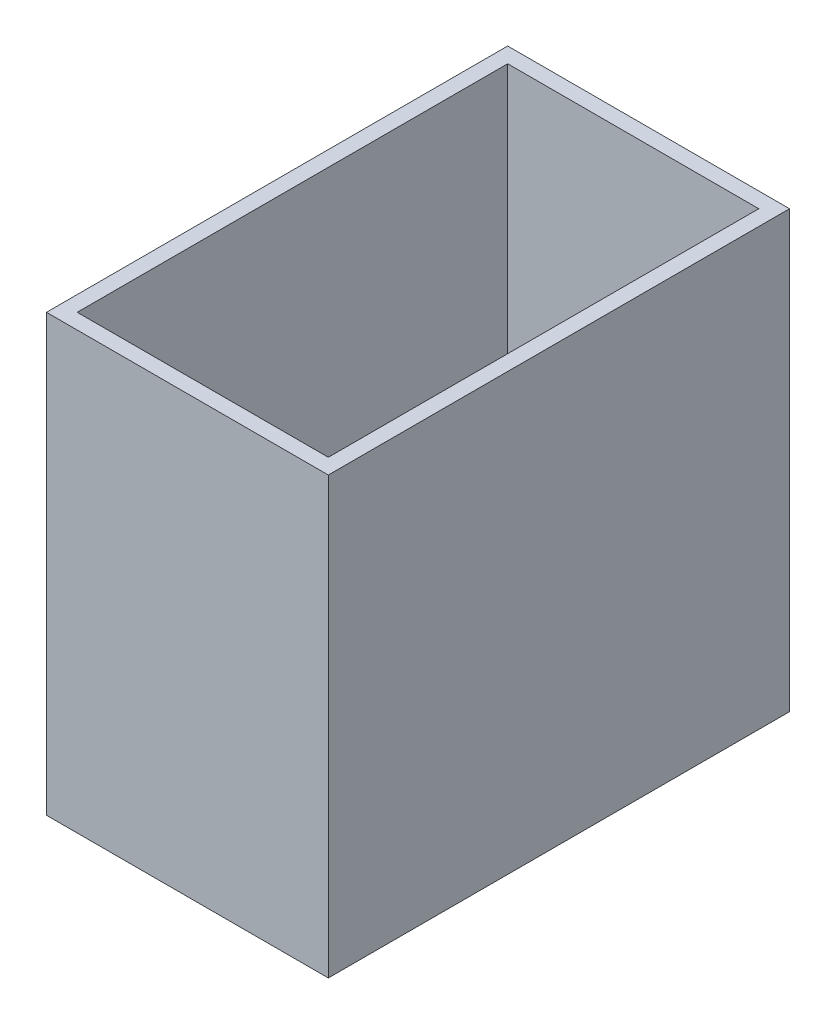
from build123d import *

# Parameters (mm, degrees)
SKETCH1_W           = 55
SKETCH1_H           = 90
BOSS_EXTRUDE1_DEPTH = 85
SHELL1_T            = -3
BOSS_EXTRUDE4_DEPTH = 87
SKETCH5_W           = 16
SKETCH5_H           = 72
CUT_EXTRUDE2_DEPTH  = 34
BOSS_EXTRUDE5_DEPTH = 52.4


with BuildPart() as part:
    # Sketch1 → Boss-Extrude1 (new body)
    with BuildSketch(Plane(origin=(0, 0, 0), x_dir=(1, 0, 0), z_dir=(0, 1, 0))):
        Rectangle(SKETCH1_W, SKETCH1_H)
    extrude(amount=BOSS_EXTRUDE1_DEPTH)

    # Shell1
    shell1_openings = [part.faces().sort_by_distance(p)[0] for p in [
        (0, 85, 0),
    ]]
    offset(amount=SHELL1_T, openings=shell1_openings, kind=Kind.INTERSECTION)

    # Sketch4 → Boss-Extrude4 (add)
    with BuildSketch(Plane.XY.offset(45)):
        Polygon((-24.5, 36), (6.5, 3), (-24.5, 3), align=None)
    extrude(amount=-BOSS_EXTRUDE4_DEPTH)

    # Sketch5 → Cut-Extrude2 (cut)
    with BuildSketch(Plane.ZY.offset(27.5)):
        Rectangle(SKETCH5_W, SKETCH5_H)
    extrude(amount=-CUT_EXTRUDE2_DEPTH, mode=Mode.SUBTRACT)

    # Sketch7 → Boss-Extrude5 (add)
    with BuildSketch(Plane(origin=(27.5, 0, 0), x_dir=(0, 0, -1), z_dir=(1, 0, 0))):
        Polygon((-42, 36), (-42, 3), (-8, 3), align=None)
        Polygon((8, 3), (42, 3), (42, 36), align=None)
    extrude(amount=-BOSS_EXTRUDE5_DEPTH)


solid = part.part
